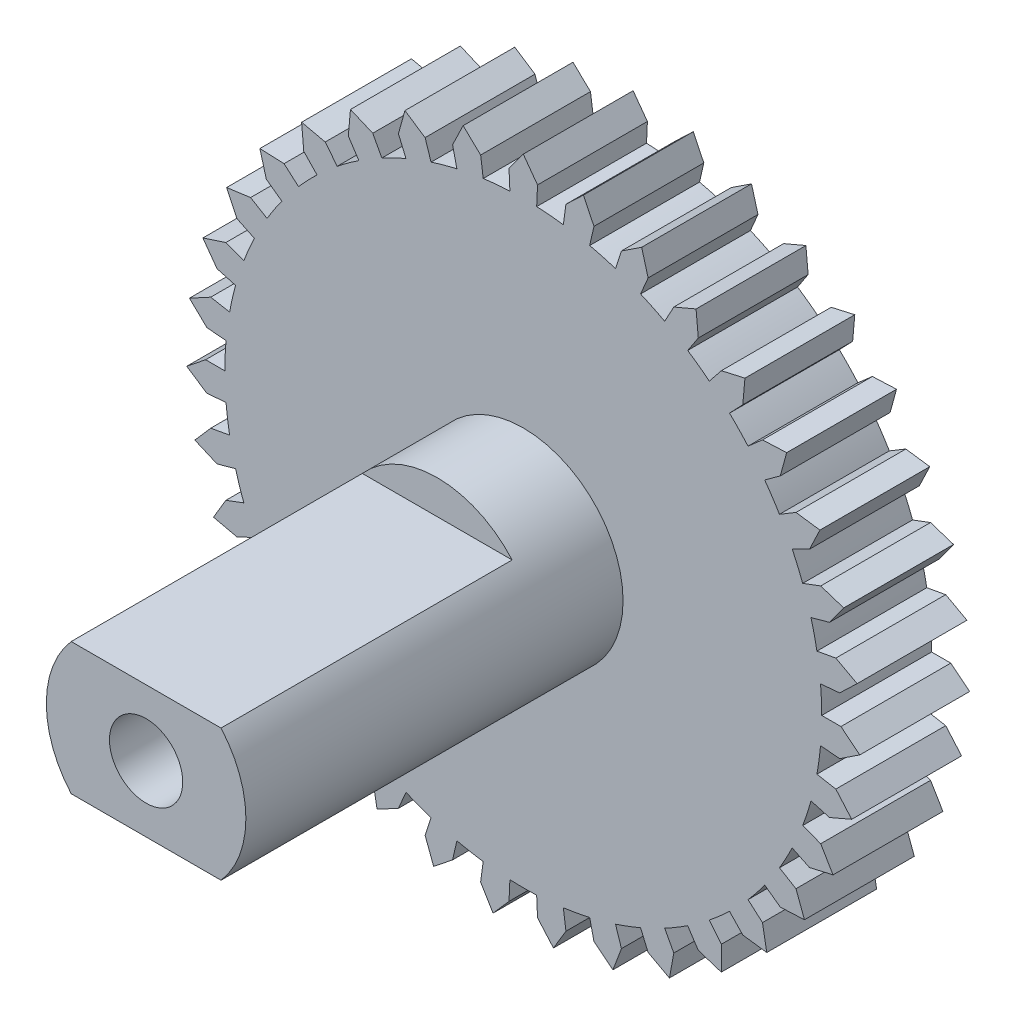
from build123d import *

# Parameters (mm, degrees)
SKETCH1_R           = 1
BOSS_EXTRUDE1_DEPTH = 3
SKETCH2_R           = 1.75
SKETCH2_R_2         = 1
BOSS_EXTRUDE2_DEPTH = 0.5
SKETCH3_R           = 2.725
SKETCH3_R_2         = 1
BOSS_EXTRUDE3_DEPTH = 10.3
CUT_EXTRUDE1_DEPTH  = 7.95


with BuildPart() as part:
    # Sketch1 → Boss-Extrude1 (new body)
    with BuildSketch(Plane.XY):
        with BuildLine():
            Line((1.642723432, 9.052152215), (1.930369102, 8.457499638))
            Line((1.930369102, 8.457499638), (1.813545612, 7.945662484))
            ThreePointArc((1.813545612, 7.945662484), (1.99137431, 7.902969591), (2.168200291, 7.856297315))
            ThreePointArc((2.168200291, 7.856297315), (2.343934519, 7.805669156), (2.518488504, 7.751110608))
            Line((2.518488504, 7.751110608), (2.680722426, 8.250415279))
            Line((2.680722426, 8.250415279), (3.232648382, 8.61336081))
            Line((3.232648382, 8.61336081), (3.409492149, 7.976903427))
            Line((3.409492149, 7.976903427), (3.203154008, 7.494151346))
            ThreePointArc((3.203154008, 7.494151346), (3.370501815, 7.420392005), (3.536152474, 7.342896273))
            ThreePointArc((3.536152474, 7.342896273), (3.700022573, 7.261703172), (3.862029599, 7.176853585))
            Line((3.862029599, 7.176853585), (4.110810647, 7.639166239))
            Line((4.110810647, 7.639166239), (4.718673352, 7.897728901))
            Line((4.718673352, 7.897728901), (4.779031314, 7.239922976))
            Line((4.779031314, 7.239922976), (4.489810399, 6.801772018))
            ThreePointArc((4.489810399, 6.801772018), (4.641298619, 6.699316915), (4.790449806, 6.593488504))
            ThreePointArc((4.790449806, 6.593488504), (4.937188857, 6.484340073), (5.081441885, 6.371926582))
            Line((5.081441885, 6.371926582), (5.408774031, 6.78238811))
            Line((5.408774031, 6.78238811), (6.053036279, 6.928257487))
            Line((6.053036279, 6.928257487), (5.99496848, 6.270245444))
            Line((5.99496848, 6.270245444), (5.632160589, 5.89077814))
            ThreePointArc((5.632160589, 5.89077814), (5.762920267, 5.762920267), (5.89077814, 5.632160589))
            ThreePointArc((5.89077814, 5.632160589), (6.01566983, 5.498564949), (6.137532448, 5.362200616))
            Line((6.137532448, 5.362200616), (6.532894968, 5.707618447))
            Line((6.532894968, 5.707618447), (7.192849639, 5.736106177))
            Line((7.192849639, 5.736106177), (7.018222426, 5.099037064))
            Line((7.018222426, 5.099037064), (6.593488504, 4.790449806))
            ThreePointArc((6.593488504, 4.790449806), (6.699316915, 4.641298619), (6.801772018, 4.489810399))
            ThreePointArc((6.801772018, 4.489810399), (6.900802224, 4.336061424), (6.996357668, 4.180129111))
            Line((6.996357668, 4.180129111), (7.447043285, 4.449401231))
            Line((7.447043285, 4.449401231), (8.101478893, 4.359591695))
            Line((8.101478893, 4.359591695), (7.815904929, 3.763941437))
            Line((7.815904929, 3.763941437), (7.342896273, 3.536152474))
            ThreePointArc((7.342896273, 3.536152474), (7.420392005, 3.370501816), (7.494151346, 3.203154008))
            ThreePointArc((7.494151346, 3.203154008), (7.564137156, 3.034193316), (7.630314196, 2.863704816))
            Line((7.630314196, 2.863704816), (8.121837503, 3.048176599))
            Line((8.121837503, 3.048176599), (8.74971995, 2.842956348))
            Line((8.74971995, 2.842956348), (8.362377816, 2.307869635))
            Line((8.362377816, 2.307869635), (7.856297315, 2.168200292))
            ThreePointArc((7.856297315, 2.168200292), (7.902969591, 1.99137431), (7.945662484, 1.813545612))
            ThreePointArc((7.945662484, 1.813545612), (7.984354497, 1.634803739), (8.019026147, 1.455238692))
            Line((8.019026147, 1.455238692), (8.535589181, 1.548981062))
            Line((8.535589181, 1.548981062), (9.116737808, 1.234946046))
            Line((9.116737808, 1.234946046), (8.640077, 0.777621005))
            Line((8.640077, 0.777621005), (8.117190496, 0.730560368))
            ThreePointArc((8.117190496, 0.730560368), (8.131539232, 0.548242396), (8.141793492, 0.365648367))
            ThreePointArc((8.141793492, 0.365648367), (8.147948115, 0.182870224), (8.15, 0))
            Line((8.15, 0), (8.675, 0))
            Line((8.675, 0), (9.190736212, -0.412756439))
            Line((9.190736212, -0.412756439), (8.640077, -0.777621005))
            Line((8.640077, -0.777621005), (8.117190496, -0.730560367))
            ThreePointArc((8.117190496, -0.730560367), (8.098754511, -0.91251048), (8.076240558, -1.094001116))
            ThreePointArc((8.076240558, -1.094001116), (8.049659976, -1.27494089), (8.019026147, -1.455238693))
            Line((8.019026147, -1.455238693), (8.535589181, -1.548981063))
            Line((8.535589181, -1.548981063), (8.969336792, -2.047192592))
            Line((8.969336792, -2.047192592), (8.362377817, -2.307869635))
            Line((8.362377817, -2.307869635), (7.856297315, -2.168200291))
            ThreePointArc((7.856297315, -2.168200291), (7.805669156, -2.343934518), (7.751110608, -2.518488504))
            ThreePointArc((7.751110608, -2.518488504), (7.692649142, -2.691774355), (7.630314196, -2.863704816))
            Line((7.630314196, -2.863704816), (8.121837503, -3.048176599))
            Line((8.121837503, -3.048176599), (8.459655507, -3.615830291))
            Line((8.459655507, -3.615830291), (7.815904929, -3.763941437))
            Line((7.815904929, -3.763941437), (7.342896273, -3.536152474))
            ThreePointArc((7.342896273, -3.536152474), (7.261703172, -3.700022573), (7.176853585, -3.862029599))
            ThreePointArc((7.176853585, -3.862029599), (7.088390235, -4.022091977), (6.996357668, -4.180129111))
            Line((6.996357668, -4.180129111), (7.447043284, -4.449401232))
            Line((7.447043284, -4.449401232), (7.678073934, -5.068252229))
            Line((7.678073934, -5.068252229), (7.018222426, -5.099037063))
            Line((7.018222426, -5.099037063), (6.593488504, -4.790449806))
            ThreePointArc((6.593488504, -4.790449806), (6.484340073, -4.937188857), (6.371926582, -5.081441885))
            ThreePointArc((6.371926582, -5.081441885), (6.256304634, -5.223136254), (6.137532448, -5.362200617))
            Line((6.137532448, -5.362200617), (6.532894967, -5.707618448))
            Line((6.532894967, -5.707618448), (6.649712747, -6.357776371))
            Line((6.649712747, -6.357776371), (5.99496848, -6.270245444))
            Line((5.99496848, -6.270245444), (5.632160589, -5.89077814))
            ThreePointArc((5.632160589, -5.89077814), (5.498564949, -6.015669829), (5.362200616, -6.137532448))
            ThreePointArc((5.362200616, -6.137532448), (5.223136254, -6.256304634), (5.081441885, -6.371926582))
            Line((5.081441885, -6.371926582), (5.408774031, -6.782388111))
            Line((5.408774031, -6.782388111), (5.407624321, -7.442956348))
            Line((5.407624321, -7.442956348), (4.779031314, -7.239922976))
            Line((4.779031314, -7.239922976), (4.489810399, -6.801772018))
            ThreePointArc((4.489810399, -6.801772018), (4.336061424, -6.900802224), (4.180129111, -6.996357668))
            ThreePointArc((4.180129111, -6.996357668), (4.022091977, -7.088390235), (3.862029599, -7.176853585))
            Line((3.862029599, -7.176853585), (4.110810647, -7.639166239))
            Line((4.110810647, -7.639166239), (3.9917304, -8.288913585))
            Line((3.9917304, -8.288913585), (3.40949215, -7.976903427))
            Line((3.40949215, -7.976903427), (3.203154008, -7.494151346))
            ThreePointArc((3.203154008, -7.494151346), (3.034193316, -7.564137156), (2.863704816, -7.630314196))
            ThreePointArc((2.863704816, -7.630314196), (2.691774355, -7.692649142), (2.518488504, -7.751110608))
            Line((2.518488504, -7.751110608), (2.680722426, -8.250415279))
            Line((2.680722426, -8.250415279), (2.447538979, -8.868458318))
            Line((2.447538979, -8.868458318), (1.930369102, -8.457499638))
            Line((1.930369102, -8.457499638), (1.813545612, -7.945662484))
            ThreePointArc((1.813545612, -7.945662484), (1.634803739, -7.984354497), (1.455238693, -8.019026147))
            ThreePointArc((1.455238693, -8.019026147), (1.27494089, -8.049659976), (1.094001116, -8.076240558))
            Line((1.094001116, -8.076240558), (1.164473581, -8.596489183))
            Line((1.164473581, -8.596489183), (0.824681642, -9.162963505))
            Line((0.824681642, -9.162963505), (0.389202404, -8.666264852))
            Line((0.389202404, -8.666264852), (0.365648368, -8.141793492))
            ThreePointArc((0.365648368, -8.141793492), (0.182870224, -8.147948115), (0, -8.15))
            ThreePointArc((0, -8.15), (-0.182870224, -8.147948115), (-0.365648368, -8.141793492))
            Line((-0.365648368, -8.141793492), (-0.389202404, -8.666264852))
            Line((-0.389202404, -8.666264852), (-0.824681642, -9.162963505))
            Line((-0.824681642, -9.162963505), (-1.164473581, -8.596489183))
            Line((-1.164473581, -8.596489183), (-1.094001116, -8.076240558))
            ThreePointArc((-1.094001116, -8.076240558), (-1.27494089, -8.049659976), (-1.455238693, -8.019026147))
            ThreePointArc((-1.455238693, -8.019026147), (-1.634803739, -7.984354497), (-1.813545612, -7.945662484))
            Line((-1.813545612, -7.945662484), (-1.930369102, -8.457499638))
            Line((-1.930369102, -8.457499638), (-2.447538979, -8.868458318))
            Line((-2.447538979, -8.868458318), (-2.680722426, -8.250415279))
            Line((-2.680722426, -8.250415279), (-2.518488504, -7.751110608))
            ThreePointArc((-2.518488504, -7.751110608), (-2.691774355, -7.692649142), (-2.863704816, -7.630314196))
            ThreePointArc((-2.863704816, -7.630314196), (-3.034193316, -7.564137156), (-3.203154008, -7.494151346))
            Line((-3.203154008, -7.494151346), (-3.40949215, -7.976903427))
            Line((-3.40949215, -7.976903427), (-3.9917304, -8.288913585))
            Line((-3.9917304, -8.288913585), (-4.110810647, -7.639166239))
            Line((-4.110810647, -7.639166239), (-3.862029599, -7.176853585))
            ThreePointArc((-3.862029599, -7.176853585), (-4.022091977, -7.088390235), (-4.180129111, -6.996357668))
            ThreePointArc((-4.180129111, -6.996357668), (-4.336061424, -6.900802224), (-4.489810399, -6.801772018))
            Line((-4.489810399, -6.801772018), (-4.779031314, -7.239922976))
            Line((-4.779031314, -7.239922976), (-5.407624321, -7.442956348))
            Line((-5.407624321, -7.442956348), (-5.408774031, -6.782388111))
            Line((-5.408774031, -6.782388111), (-5.081441885, -6.371926582))
            ThreePointArc((-5.081441885, -6.371926582), (-5.223136254, -6.256304634), (-5.362200616, -6.137532448))
            ThreePointArc((-5.362200616, -6.137532448), (-5.498564949, -6.015669829), (-5.632160589, -5.89077814))
            Line((-5.632160589, -5.89077814), (-5.99496848, -6.270245444))
            Line((-5.99496848, -6.270245444), (-6.649712747, -6.357776371))
            Line((-6.649712747, -6.357776371), (-6.532894967, -5.707618448))
            Line((-6.532894967, -5.707618448), (-6.137532448, -5.362200617))
            ThreePointArc((-6.137532448, -5.362200617), (-6.256304634, -5.223136254), (-6.371926582, -5.081441885))
            ThreePointArc((-6.371926582, -5.081441885), (-6.484340073, -4.937188857), (-6.593488504, -4.790449806))
            Line((-6.593488504, -4.790449806), (-7.018222426, -5.099037063))
            Line((-7.018222426, -5.099037063), (-7.678073934, -5.068252229))
            Line((-7.678073934, -5.068252229), (-7.447043284, -4.449401232))
            Line((-7.447043284, -4.449401232), (-6.996357668, -4.180129111))
            ThreePointArc((-6.996357668, -4.180129111), (-7.088390235, -4.022091977), (-7.176853585, -3.862029599))
            ThreePointArc((-7.176853585, -3.862029599), (-7.261703172, -3.700022573), (-7.342896273, -3.536152474))
            Line((-7.342896273, -3.536152474), (-7.815904929, -3.763941437))
            Line((-7.815904929, -3.763941437), (-8.459655507, -3.615830291))
            Line((-8.459655507, -3.615830291), (-8.121837503, -3.048176599))
            Line((-8.121837503, -3.048176599), (-7.630314196, -2.863704816))
            ThreePointArc((-7.630314196, -2.863704816), (-7.692649142, -2.691774355), (-7.751110608, -2.518488504))
            ThreePointArc((-7.751110608, -2.518488504), (-7.805669156, -2.343934518), (-7.856297315, -2.168200291))
            Line((-7.856297315, -2.168200291), (-8.362377817, -2.307869635))
            Line((-8.362377817, -2.307869635), (-8.969336792, -2.047192592))
            Line((-8.969336792, -2.047192592), (-8.535589181, -1.548981063))
            Line((-8.535589181, -1.548981063), (-8.019026147, -1.455238693))
            ThreePointArc((-8.019026147, -1.455238693), (-8.049659976, -1.27494089), (-8.076240558, -1.094001116))
            ThreePointArc((-8.076240558, -1.094001116), (-8.098754511, -0.91251048), (-8.117190496, -0.730560367))
            Line((-8.117190496, -0.730560367), (-8.640077, -0.777621005))
            Line((-8.640077, -0.777621005), (-9.190736212, -0.412756439))
            Line((-9.190736212, -0.412756439), (-8.675, 0))
            Line((-8.675, 0), (-8.15, 0))
            ThreePointArc((-8.15, 0), (-8.147948115, 0.182870224), (-8.141793492, 0.365648367))
            ThreePointArc((-8.141793492, 0.365648367), (-8.131539232, 0.548242396), (-8.117190496, 0.730560368))
            Line((-8.117190496, 0.730560368), (-8.640077, 0.777621005))
            Line((-8.640077, 0.777621005), (-9.116737808, 1.234946046))
            Line((-9.116737808, 1.234946046), (-8.535589181, 1.548981062))
            Line((-8.535589181, 1.548981062), (-8.019026147, 1.455238692))
            ThreePointArc((-8.019026147, 1.455238692), (-7.984354497, 1.634803739), (-7.945662484, 1.813545612))
            ThreePointArc((-7.945662484, 1.813545612), (-7.902969591, 1.99137431), (-7.856297315, 2.168200292))
            Line((-7.856297315, 2.168200292), (-8.362377816, 2.307869635))
            Line((-8.362377816, 2.307869635), (-8.74971995, 2.842956348))
            Line((-8.74971995, 2.842956348), (-8.121837503, 3.048176599))
            Line((-8.121837503, 3.048176599), (-7.630314196, 2.863704816))
            ThreePointArc((-7.630314196, 2.863704816), (-7.564137156, 3.034193316), (-7.494151346, 3.203154008))
            ThreePointArc((-7.494151346, 3.203154008), (-7.420392005, 3.370501816), (-7.342896273, 3.536152474))
            Line((-7.342896273, 3.536152474), (-7.815904929, 3.763941437))
            Line((-7.815904929, 3.763941437), (-8.101478893, 4.359591695))
            Line((-8.101478893, 4.359591695), (-7.447043285, 4.449401231))
            Line((-7.447043285, 4.449401231), (-6.996357668, 4.180129111))
            ThreePointArc((-6.996357668, 4.180129111), (-6.900802224, 4.336061424), (-6.801772018, 4.489810399))
            ThreePointArc((-6.801772018, 4.489810399), (-6.699316915, 4.641298619), (-6.593488504, 4.790449806))
            Line((-6.593488504, 4.790449806), (-7.018222426, 5.099037064))
            Line((-7.018222426, 5.099037064), (-7.192849639, 5.736106177))
            Line((-7.192849639, 5.736106177), (-6.532894968, 5.707618447))
            Line((-6.532894968, 5.707618447), (-6.137532448, 5.362200616))
            ThreePointArc((-6.137532448, 5.362200616), (-6.01566983, 5.498564949), (-5.89077814, 5.632160589))
            ThreePointArc((-5.89077814, 5.632160589), (-5.762920267, 5.762920267), (-5.632160589, 5.89077814))
            Line((-5.632160589, 5.89077814), (-5.99496848, 6.270245444))
            Line((-5.99496848, 6.270245444), (-6.053036279, 6.928257487))
            Line((-6.053036279, 6.928257487), (-5.408774031, 6.78238811))
            Line((-5.408774031, 6.78238811), (-5.081441885, 6.371926582))
            ThreePointArc((-5.081441885, 6.371926582), (-4.937188857, 6.484340073), (-4.790449806, 6.593488504))
            ThreePointArc((-4.790449806, 6.593488504), (-4.641298619, 6.699316915), (-4.489810399, 6.801772018))
            Line((-4.489810399, 6.801772018), (-4.779031314, 7.239922976))
            Line((-4.779031314, 7.239922976), (-4.718673352, 7.897728901))
            Line((-4.718673352, 7.897728901), (-4.110810647, 7.639166239))
            Line((-4.110810647, 7.639166239), (-3.862029599, 7.176853585))
            ThreePointArc((-3.862029599, 7.176853585), (-3.700022573, 7.261703172), (-3.536152474, 7.342896273))
            ThreePointArc((-3.536152474, 7.342896273), (-3.370501815, 7.420392005), (-3.203154008, 7.494151346))
            Line((-3.203154008, 7.494151346), (-3.409492149, 7.976903427))
            Line((-3.409492149, 7.976903427), (-3.232648382, 8.61336081))
            Line((-3.232648382, 8.61336081), (-2.680722426, 8.250415279))
            Line((-2.680722426, 8.250415279), (-2.518488504, 7.751110608))
            ThreePointArc((-2.518488504, 7.751110608), (-2.343934519, 7.805669156), (-2.168200291, 7.856297315))
            ThreePointArc((-2.168200291, 7.856297315), (-1.99137431, 7.902969591), (-1.813545612, 7.945662484))
            Line((-1.813545612, 7.945662484), (-1.930369102, 8.457499638))
            Line((-1.930369102, 8.457499638), (-1.642723432, 9.052152215))
            Line((-1.642723432, 9.052152215), (-1.164473581, 8.596489183))
            Line((-1.164473581, 8.596489183), (-1.094001117, 8.076240558))
            ThreePointArc((-1.094001117, 8.076240558), (-0.91251048, 8.098754511), (-0.730560368, 8.117190496))
            ThreePointArc((-0.730560368, 8.117190496), (-0.548242396, 8.131539232), (-0.365648367, 8.141793492))
            Line((-0.365648367, 8.141793492), (-0.389202403, 8.666264852))
            Line((-0.389202403, 8.666264852), (0, 9.2))
            Line((0, 9.2), (0.389202403, 8.666264852))
            Line((0.389202403, 8.666264852), (0.365648367, 8.141793492))
            ThreePointArc((0.365648367, 8.141793492), (0.548242396, 8.131539232), (0.730560368, 8.117190496))
            ThreePointArc((0.730560368, 8.117190496), (0.91251048, 8.098754511), (1.094001117, 8.076240558))
            Line((1.094001117, 8.076240558), (1.164473581, 8.596489183))
            Line((1.164473581, 8.596489183), (1.642723432, 9.052152215))
        make_face()
        Circle(SKETCH1_R, mode=Mode.SUBTRACT)
    extrude(amount=BOSS_EXTRUDE1_DEPTH)

    # Sketch2 → Boss-Extrude2 (add)
    with BuildSketch(Plane(origin=(0, 0, 0), x_dir=(-1, 0, 0), z_dir=(0, 0, -1))):
        Circle(SKETCH2_R)
        Circle(SKETCH2_R_2, mode=Mode.SUBTRACT)
    extrude(amount=BOSS_EXTRUDE2_DEPTH)

    # Sketch3 → Boss-Extrude3 (add)
    with BuildSketch(Plane.XY.offset(3)):
        Circle(SKETCH3_R)
        Circle(SKETCH3_R_2, mode=Mode.SUBTRACT)
    extrude(amount=BOSS_EXTRUDE3_DEPTH)

    # Sketch4 → Cut-Extrude1 (cut)
    with BuildSketch(Plane.XY.offset(13.3)):
        with BuildLine():
            Line((-2.045880006, -1.8), (2.045880006, -1.8))
            ThreePointArc((2.045880006, -1.8), (0, -2.725), (-2.045880006, -1.8))
        make_face()
        with BuildLine():
            Line((-2.045880006, 1.8), (2.045880006, 1.8))
            ThreePointArc((2.045880006, 1.8), (0, 2.725), (-2.045880006, 1.8))
        make_face()
    extrude(amount=-CUT_EXTRUDE1_DEPTH, mode=Mode.SUBTRACT)


solid = part.part
